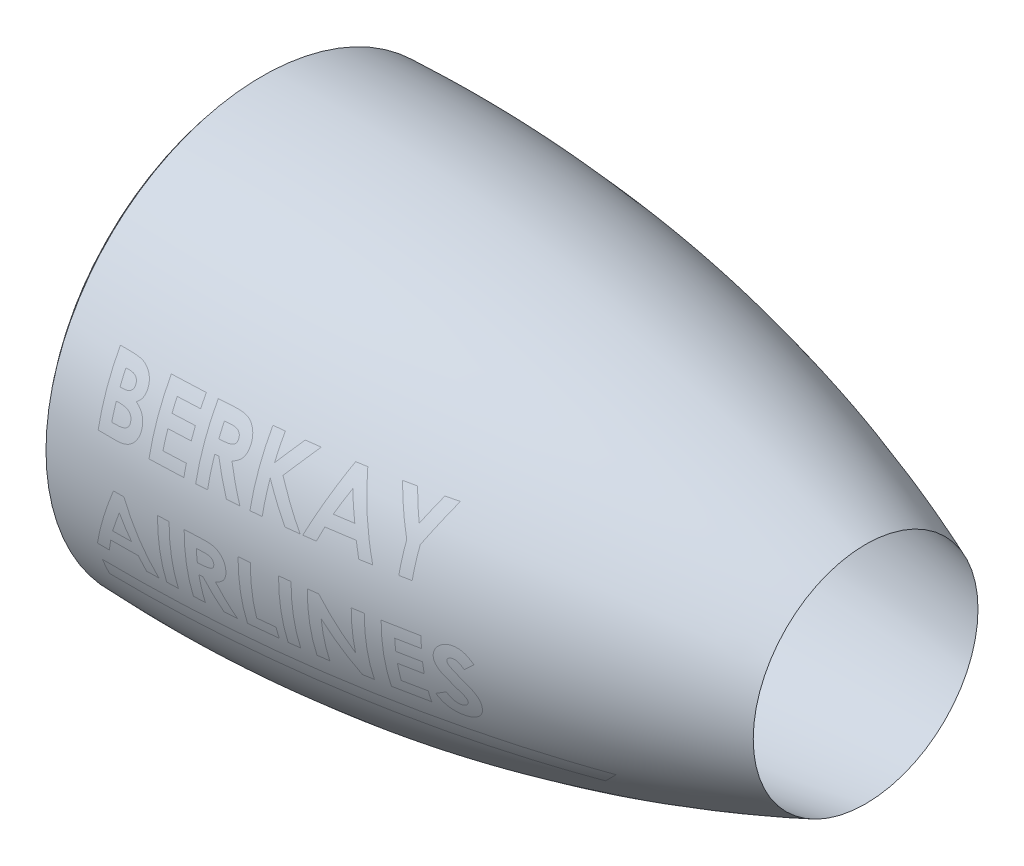
from build123d import *

# Parameters (mm, degrees)
THICKEN1_T2 = 5


with BuildPart() as body_1:
    # Surface-Revolve1: a surface, the sketch's curves turned about an axis
    with BuildLine(Plane.XY, mode=Mode.PRIVATE) as surface_revolve1_1_path:
        Line((0, 180), (25, 180))
        Line((25, 180), (35, 190))
        Line((35, 190), (60, 190))
        Line((60, 190), (580, 108))
        add(Edge.make_bspline(
            [(580, 108), (300.524449477, 219.989910698), (0, 207.588720813)],
            knots=[0, 0, 0, 1, 1, 1], degree=2))
        add(Edge.make_bspline(
            [(0, 207.588720813), (-15.420167335, 191.948492481), (0, 180)],
            knots=[0, 0, 0, 1, 1, 1], degree=2))
    surface_revolve1_1 = Shell.revolve(surface_revolve1_1_path.wire(), 360, Axis((675.305703984, 0, 0), (-1, 0, 0)))
    add(Solid.thicken(surface_revolve1_1, -THICKEN1_T2))


solid = body_1.part
